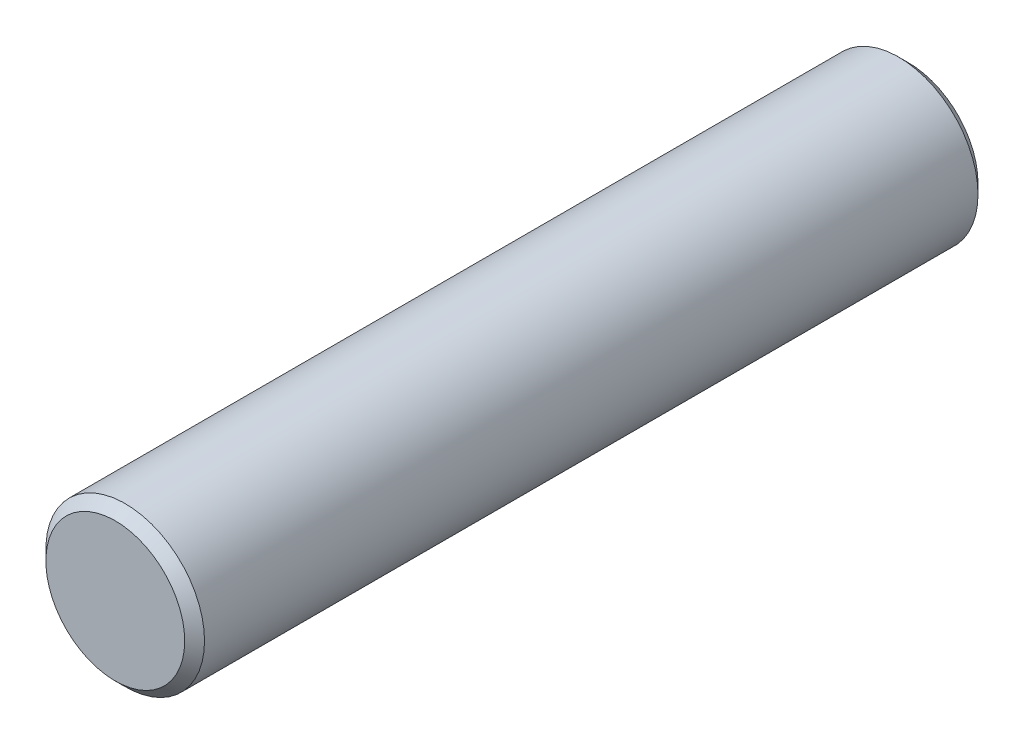
from build123d import *

# Parameters (mm, degrees)
SKETCH_1_R      = 4
EXTRUDE_1_DEPTH = 40
CHAMFER_1_SIZE  = 0.5


with BuildPart() as part:
    # 草圖1 → 填料-伸長1 (new body)
    with BuildSketch(Plane.XY):
        Circle(SKETCH_1_R)
    extrude(amount=EXTRUDE_1_DEPTH)

    # 導角1
    chamfer_1_edges = [part.edges().sort_by_distance(p)[0] for p in [
        (-4, 0, 0),
        (-4, 0, 40),
    ]]
    chamfer(chamfer_1_edges, length=CHAMFER_1_SIZE)


solid = part.part
